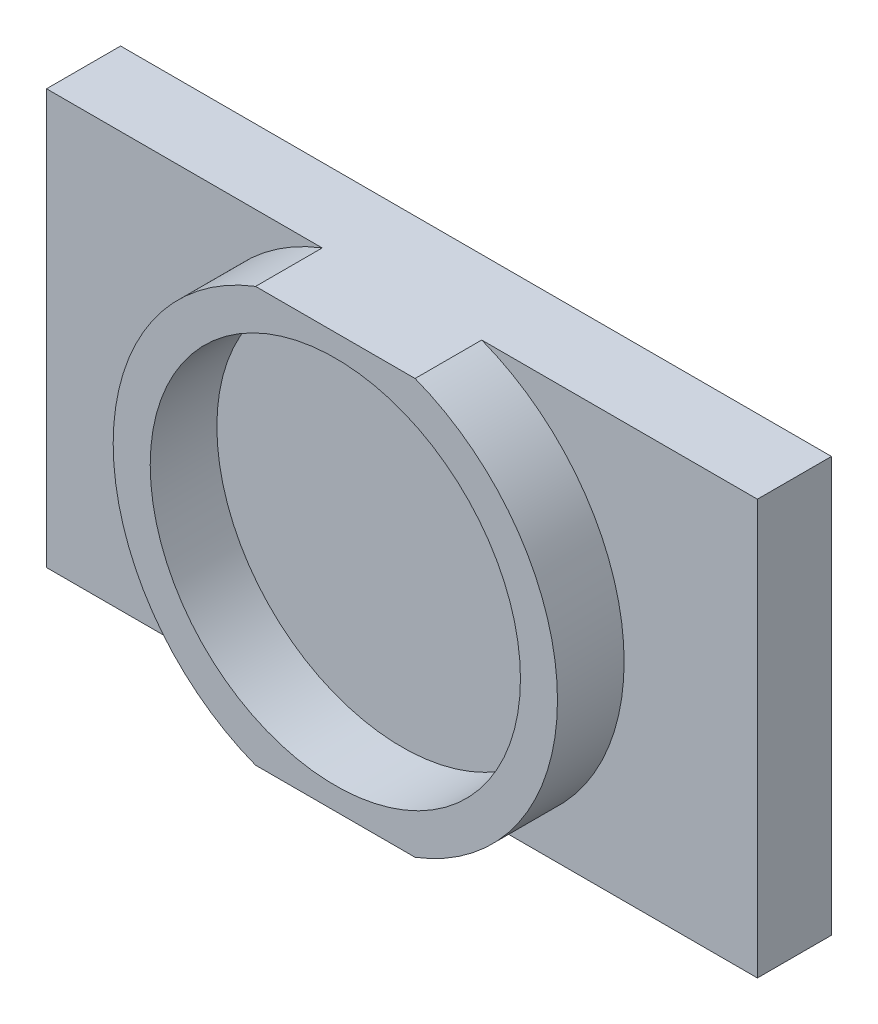
from build123d import *

# Parameters (mm, degrees)
SKETCH2_W           = 121.92
SKETCH2_H           = 71.12
BOSS_EXTRUDE1_DEPTH = 12.7
SKETCH3_R           = 31.75
BOSS_EXTRUDE2_DEPTH = 11.43


with BuildPart() as part:
    # Sketch2 → Boss-Extrude1 (new body)
    with BuildSketch(Plane.XY):
        Rectangle(SKETCH2_W, SKETCH2_H)
    extrude(amount=-BOSS_EXTRUDE1_DEPTH)

    # Sketch3 → Boss-Extrude2 (add)
    with BuildSketch(Plane.XY):
        with BuildLine():
            Line((-13.67831861, 35.56), (13.67831861, 35.56))
            ThreePointArc((13.67831861, 35.56), (38.1, 0), (13.67831861, -35.56))
            Line((13.67831861, -35.56), (-13.67831861, -35.56))
            ThreePointArc((-13.67831861, -35.56), (-38.1, 0), (-13.67831861, 35.56))
        make_face()
        Circle(SKETCH3_R, mode=Mode.SUBTRACT)
    extrude(amount=BOSS_EXTRUDE2_DEPTH)


solid = part.part
